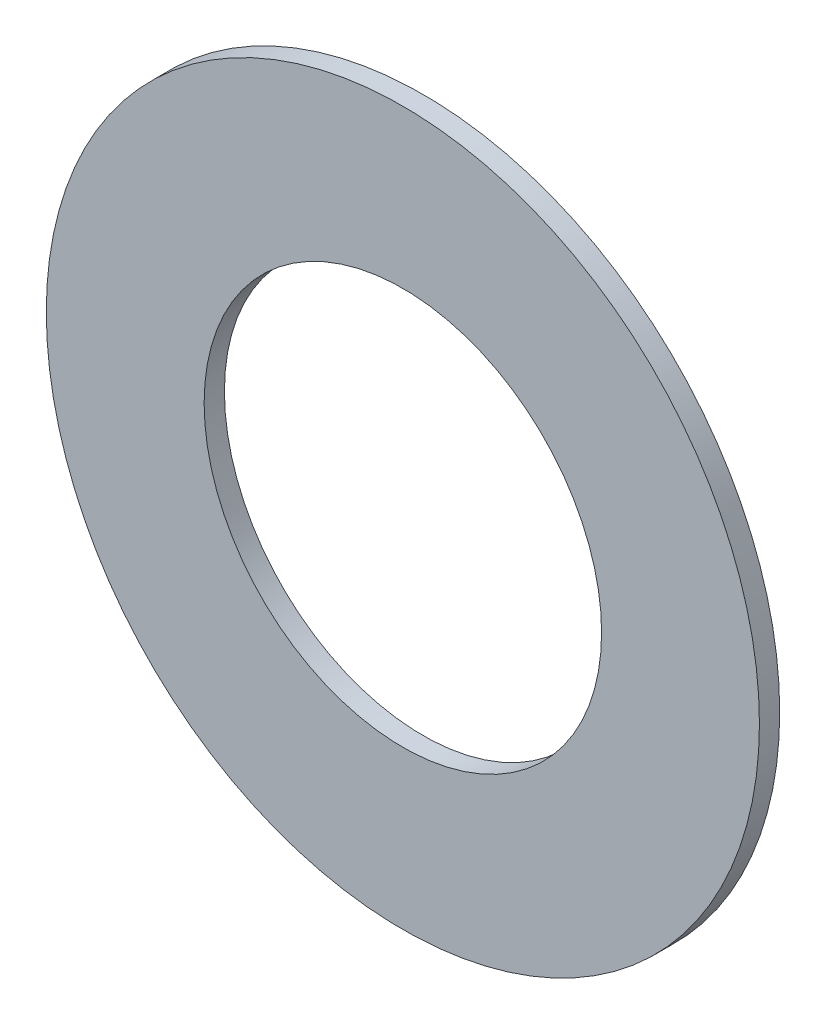
from build123d import *

# Parameters (mm, degrees)
SKETCH3_R                = 14.2875
SKETCH3_R_2              = 7.9629
BOSS_EXTRUDE1_DEPTH      = 0.4064
BOSS_EXTRUDE1_DEPTH_BACK = 0.4064


with BuildPart() as part:
    # Sketch3 → Boss-Extrude1 (new body, two sides)
    with BuildSketch(Plane.XY) as boss_extrude1_sk:
        Circle(SKETCH3_R)
        Circle(SKETCH3_R_2, mode=Mode.SUBTRACT)
    extrude(amount=BOSS_EXTRUDE1_DEPTH)
    extrude(boss_extrude1_sk.sketch, amount=-BOSS_EXTRUDE1_DEPTH_BACK)


solid = part.part
